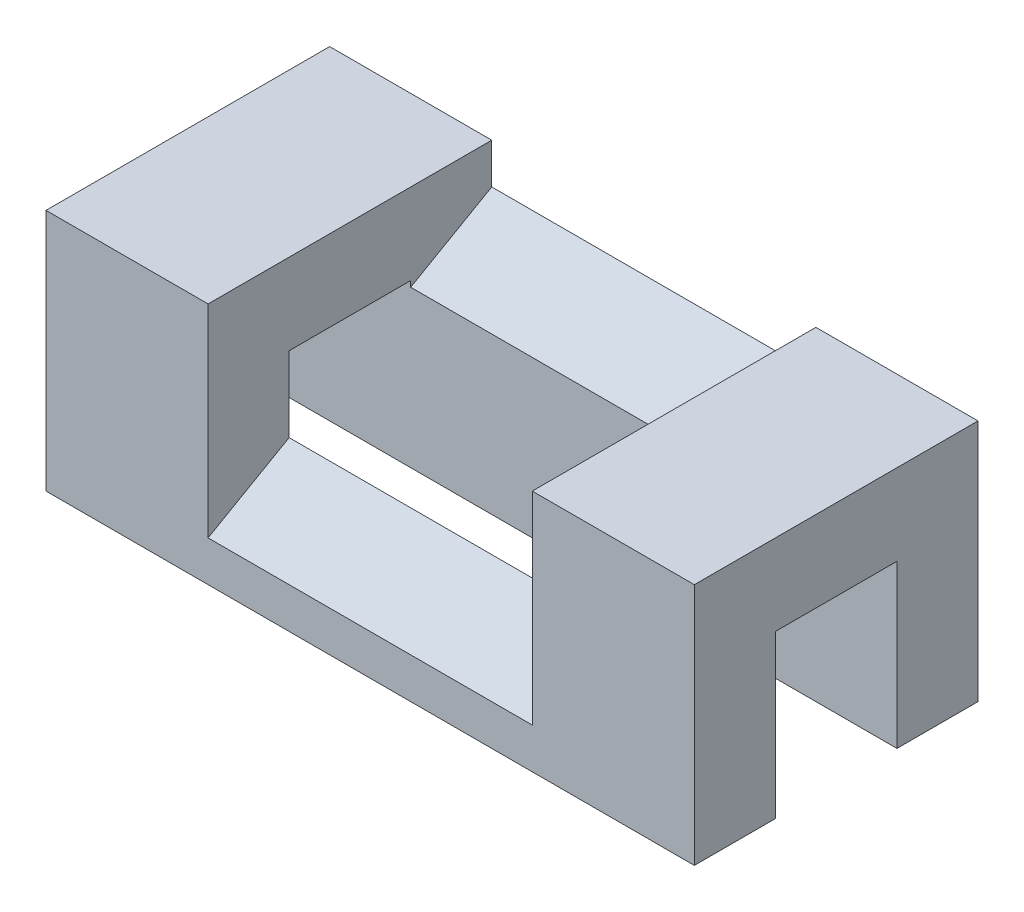
from build123d import *

# Parameters (mm, degrees)
BOSS_EXTRUDE1_DEPTH = 40
CUT_EXTRUDE2_DEPTH  = 20


with BuildPart() as part:
    # Sketch1 → Boss-Extrude1 (new body, symmetric)
    with BuildSketch(Plane(origin=(0, 0, 0), x_dir=(0, 0, -1), z_dir=(1, 0, 0))):
        Polygon((0, 0), (0, 30), (35, 30), (35, 0), (25, 0), (25, 20), (10, 20), (10, 0), align=None)
    extrude(amount=BOSS_EXTRUDE1_DEPTH, both=True)

    # Sketch2 → Cut-Extrude2 (cut, symmetric)
    with BuildSketch(Plane(origin=(0, 0, 0), x_dir=(0, 0, -1), z_dir=(1, 0, 0))):
        Polygon((35, 25), (0, 5), (0, 30), (35, 30), align=None)
    extrude(amount=CUT_EXTRUDE2_DEPTH, both=True, mode=Mode.SUBTRACT)


solid = part.part
